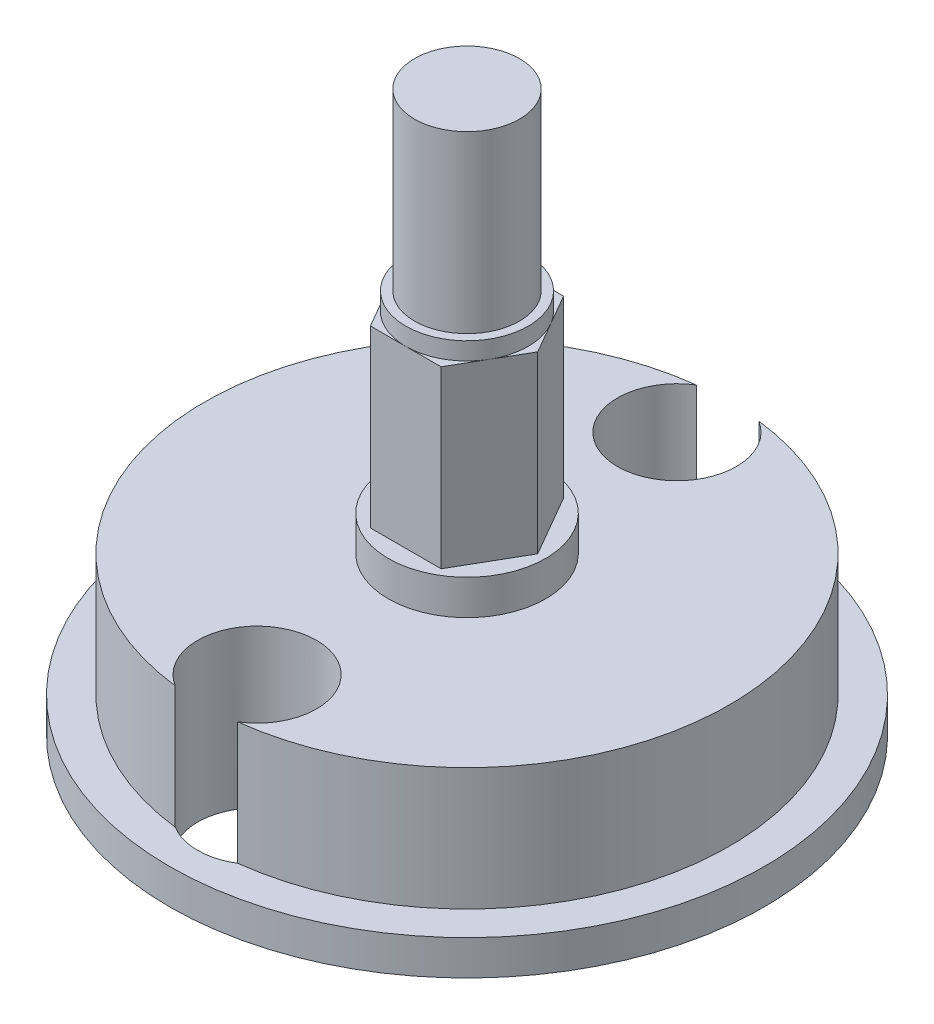
from build123d import *

# Parameters (mm, degrees)
SKETCH_1_R         = 7.5
EXTRUDE_1_DEPTH    = 4.5
SKETCH_9_R         = 2.25
EXTRUDE_6_DEPTH    = 1
EXTRUDE_2_DEPTH    = 5
SKETCH_6_R         = 1.75
EXTRUDE_3_DEPTH    = 0.5
SKETCH_7_R         = 1.5
EXTRUDE_4_DEPTH    = 5
SKETCH_8_R         = 8.5
SKETCH_8_R_2       = 7.5
EXTRUDE_5_DEPTH    = 1
HOLE_WIZARD_M3_1_D = 3.4


with BuildPart() as part:
    # ｽｹｯﾁ1 → ﾎﾞｽ - 押し出し1 (new body)
    with BuildSketch(Plane(origin=(0, 0, 0), x_dir=(1, 0, 0), z_dir=(0, 1, 0))):
        Circle(SKETCH_1_R)
    extrude(amount=EXTRUDE_1_DEPTH)

    # ｽｹｯﾁ9 → ﾎﾞｽ - 押し出し6 (add)
    with BuildSketch(Plane(origin=(0, 4.5, 0), x_dir=(1, 0, 0), z_dir=(0, 1, 0))):
        Circle(SKETCH_9_R)
    extrude(amount=EXTRUDE_6_DEPTH)

    # ｽｹｯﾁ2 → ﾎﾞｽ - 押し出し2 (add)
    with BuildSketch(Plane(origin=(0, 5.5, 0), x_dir=(1, 0, 0), z_dir=(0, 1, 0))):
        Polygon((2.020725942, 0), (1.010362971, 1.75), (-1.010362971, 1.75), (-2.020725942, 0), (-1.010362971, -1.75), (1.010362971, -1.75), align=None)
    extrude(amount=EXTRUDE_2_DEPTH)

    # ｽｹｯﾁ6 → ﾎﾞｽ - 押し出し3 (add)
    with BuildSketch(Plane(origin=(0, 10.5, 0), x_dir=(1, 0, 0), z_dir=(0, 1, 0))):
        Circle(SKETCH_6_R)
    extrude(amount=EXTRUDE_3_DEPTH)

    # ｽｹｯﾁ7 → ﾎﾞｽ - 押し出し4 (add)
    with BuildSketch(Plane(origin=(0, 11, 0), x_dir=(1, 0, 0), z_dir=(0, 1, 0))):
        Circle(SKETCH_7_R)
    extrude(amount=EXTRUDE_4_DEPTH)

    # ｽｹｯﾁ8 → ﾎﾞｽ - 押し出し5 (add)
    with BuildSketch(Plane(origin=(0, 0, 0), x_dir=(-1, 0, 0), z_dir=(0, -1, 0))):
        Circle(SKETCH_8_R)
        Circle(SKETCH_8_R_2, mode=Mode.SUBTRACT)
    extrude(amount=-EXTRUDE_5_DEPTH)

    # M3 すきま穴1 (through all)
    with Locations(Plane(origin=(0, 4.5, 0), x_dir=(1, 0, 0), z_dir=(0, 1, 0))):
        with Locations((0, 6), (0, -6)):
            Hole(HOLE_WIZARD_M3_1_D / 2)


solid = part.part
